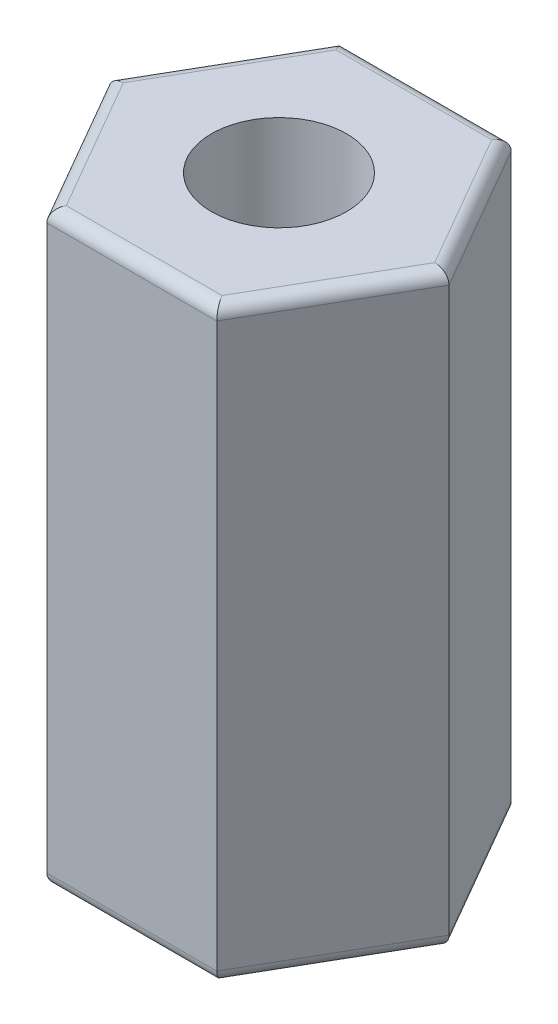
from build123d import *

# Parameters (mm, degrees)
RESSALTO_EXTRUS_O1_DEPTH = 9.5
FILETE1_R                = 0.2
ESBO_O3_R                = 1.0922
CORTE_EXTRUS_O1_DEPTH    = 4.76
ESBO_O2_R                = 1.0922
CORTE_EXTRUS_O2_DEPTH    = 10.5


with BuildPart() as part:
    # Esboço1 → Ressalto-extrusão1 (new body)
    with BuildSketch(Plane(origin=(0, 0, 0), x_dir=(1, 0, 0), z_dir=(0, 1, 0))):
        Polygon((2.748187281, 0), (1.374093641, 2.38), (-1.374093641, 2.38), (-2.748187281, 0), (-1.374093641, -2.38), (1.374093641, -2.38), align=None)
    extrude(amount=RESSALTO_EXTRUS_O1_DEPTH)

    # Filete1
    filete1_edges = [part.edges().sort_by_distance(p)[0] for p in [
        (0, 9.5, -2.38),
        (-2.061140461, 9.5, -1.19),
        (-2.061140461, 9.5, 1.19),
        (0, 9.5, 2.38),
        (2.061140461, 9.5, 1.19),
        (0, 0, 2.38),
        (-2.061140461, 0, 1.19),
        (-2.061140461, 0, -1.19),
        (2.061140461, 9.5, -1.19),
        (0, 0, -2.38),
        (2.061140461, 0, -1.19),
        (2.061140461, 0, 1.19),
    ]]
    fillet(filete1_edges, radius=FILETE1_R)

    # Esboço3 → Corte-extrusão1 (cut)
    with BuildSketch(Plane(origin=(0, 9.5, 0), x_dir=(1, 0, 0), z_dir=(0, 1, 0))):
        Circle(ESBO_O3_R)
    extrude(amount=-CORTE_EXTRUS_O1_DEPTH, mode=Mode.SUBTRACT)

    # Esboço2 → Corte-extrusão2 (cut, through all)
    with BuildSketch(Plane.XZ):
        Circle(ESBO_O2_R)
    extrude(amount=-CORTE_EXTRUS_O2_DEPTH, mode=Mode.SUBTRACT)


solid = part.part
